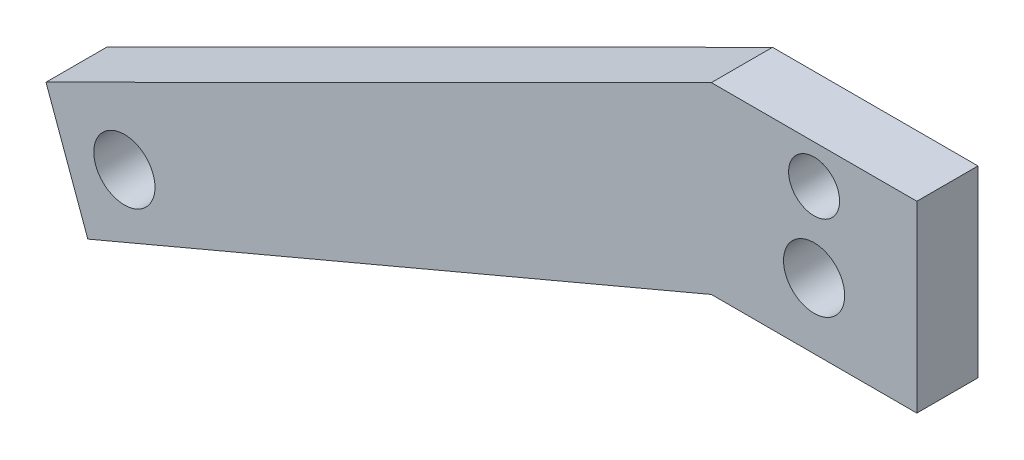
from build123d import *

# Parameters (mm, degrees)
SKETCH1_R           = 3.968750002
SKETCH1_R_2         = 4.762500002
BOSS_EXTRUDE1_DEPTH = 9.525


with BuildPart() as part:
    # Sketch1 → Boss-Extrude1 (new body)
    with BuildSketch(Plane.XY):
        Polygon((-15.999994627, 44.999976621), (-119.615175298, -6.752498345), (-113.099691568, -24.653642771), (-15.999994627, 16.424976621), (16.000005373, 16.424976621), (16.000005373, 44.999976621), align=None)
        with Locations((5.373e-06, 38.999976621)):
            Circle(SKETCH1_R, mode=Mode.SUBTRACT)
        with Locations((5.336e-06, 26.647573689)):
            Circle(SKETCH1_R_2, mode=Mode.SUBTRACT)
        with Locations((-107.40686122, -12.445328693)):
            Circle(SKETCH1_R_2, mode=Mode.SUBTRACT)
    extrude(amount=BOSS_EXTRUDE1_DEPTH)


solid = part.part
